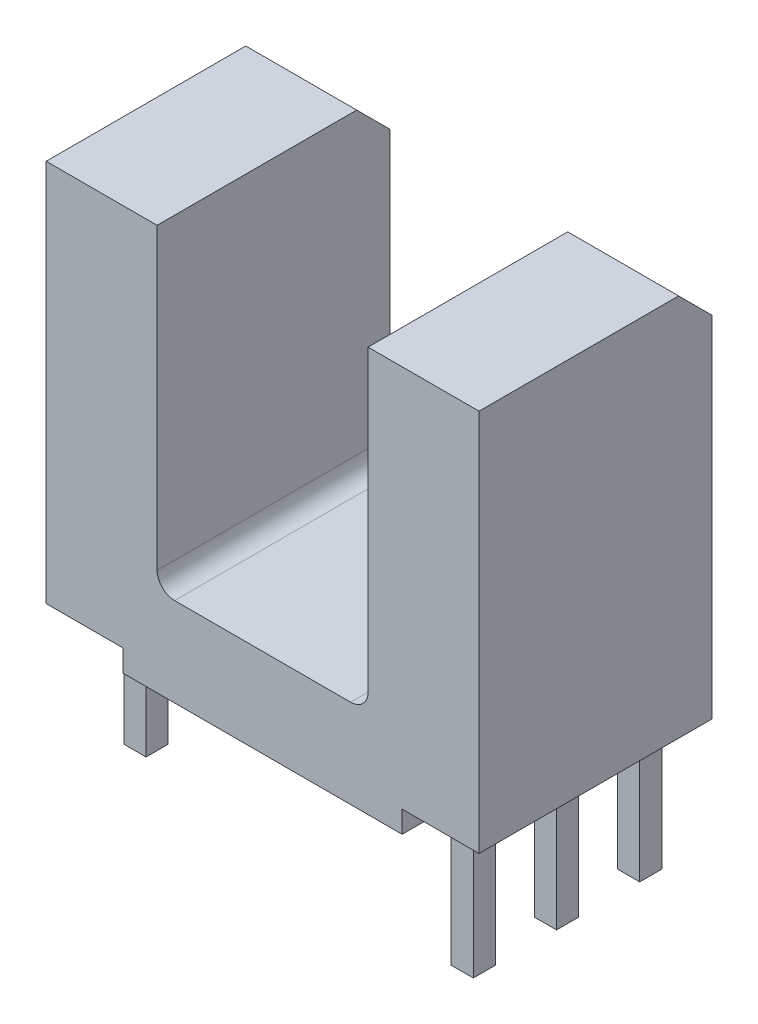
from build123d import *

# Parameters (mm, degrees)
BOSS_EXTRUDE1_DEPTH      = 2.665
CHAMFER1_SIZE            = 0.76
SKETCH2_W                = 1.76
SKETCH2_H                = 5.33
CUT_EXTRUDE1_DEPTH       = 0.5
FILLET1_R                = 0.4
SKETCH3_W                = 0.508
SKETCH3_H                = 0.508
BOSS_EXTRUDE2_DEPTH      = 2.54
BOSS_EXTRUDE2_DEPTH_BACK = 0.5


with BuildPart() as part:
    # Sketch1 → Boss-Extrude1 (new body, symmetric)
    with BuildSketch(Plane.XY):
        Polygon((2.415, 9.27), (4.955, 9.27), (4.955, 0), (-4.955, 0), (-4.955, 9.27), (-2.415, 9.27), (-2.415, 2.03), (2.415, 2.03), align=None)
    extrude(amount=BOSS_EXTRUDE1_DEPTH, both=True)

    # Chamfer1
    chamfer1_edges = [part.edges().sort_by_distance(p)[0] for p in [
        (-4.955, 4.635, -2.665),
        (-3.685, 9.27, -2.665),
        (3.685, 9.27, -2.665),
    ]]
    chamfer(chamfer1_edges, length=CHAMFER1_SIZE)

    # Sketch2 → Cut-Extrude1 (cut)
    with BuildSketch(Plane.XZ):
        with Locations((-4.075, 0)):
            Rectangle(SKETCH2_W, SKETCH2_H)
        with Locations((4.075, 0)):
            Rectangle(SKETCH2_W, SKETCH2_H)
    extrude(amount=-CUT_EXTRUDE1_DEPTH, mode=Mode.SUBTRACT)

    # Fillet1
    fillet1_edges = [part.edges().sort_by_distance(p)[0] for p in [
        (-2.415, 2.03, 0),
        (2.415, 2.03, 0),
    ]]
    fillet(fillet1_edges, radius=FILLET1_R)

    # Sketch3 → Boss-Extrude2 (add, two sides)
    with BuildSketch(Plane.XZ) as boss_extrude2_sk:
        with Locations((4.064, 0)):
            Rectangle(SKETCH3_W, SKETCH3_H)
        with Locations((-4.064, 1.27)):
            Rectangle(SKETCH3_W, SKETCH3_H)
        with Locations((-4.064, -1.27)):
            Rectangle(SKETCH3_W, SKETCH3_H)
        with Locations((4.064, 1.905)):
            Rectangle(SKETCH3_W, SKETCH3_H)
        with Locations((4.064, -1.905)):
            Rectangle(SKETCH3_W, SKETCH3_H)
    extrude(amount=BOSS_EXTRUDE2_DEPTH)
    extrude(boss_extrude2_sk.sketch, amount=-BOSS_EXTRUDE2_DEPTH_BACK)


solid = part.part
